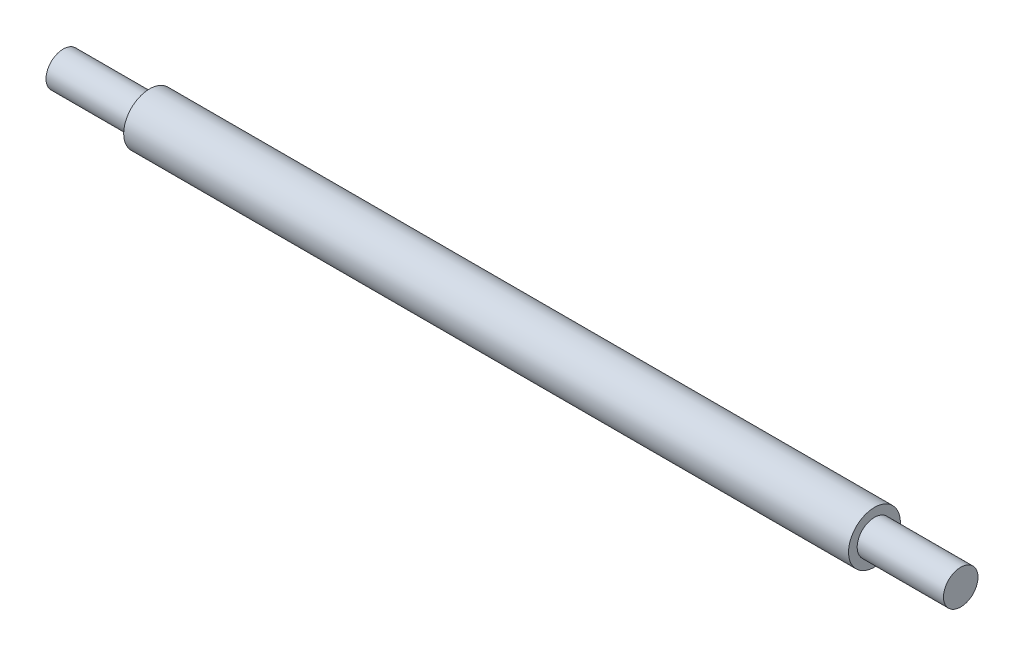
from build123d import *

# Parameters (mm, degrees)
IZIM1_R                     = 2
Y_KSEKLIK_EKSTR_ZYON1_DEPTH = 10
IZIM2_R                     = 3
Y_KSEKLIK_EKSTR_ZYON2_DEPTH = 84
IZIM3_R                     = 2
Y_KSEKLIK_EKSTR_ZYON3_DEPTH = 10


with BuildPart() as part:
    # Çizim1 → Yükseklik-Ekstrüzyon1 (new body)
    with BuildSketch(Plane(origin=(0, 0, 0), x_dir=(0, 0, -1), z_dir=(1, 0, 0))):
        Circle(IZIM1_R)
    extrude(amount=-Y_KSEKLIK_EKSTR_ZYON1_DEPTH)

    # Çizim2 → Yükseklik-Ekstrüzyon2 (add)
    with BuildSketch(Plane.ZY.offset(10)):
        Circle(IZIM2_R)
    extrude(amount=Y_KSEKLIK_EKSTR_ZYON2_DEPTH)

    # Çizim3 → Yükseklik-Ekstrüzyon3 (add)
    with BuildSketch(Plane.ZY.offset(94)):
        Circle(IZIM3_R)
    extrude(amount=Y_KSEKLIK_EKSTR_ZYON3_DEPTH)


solid = part.part
